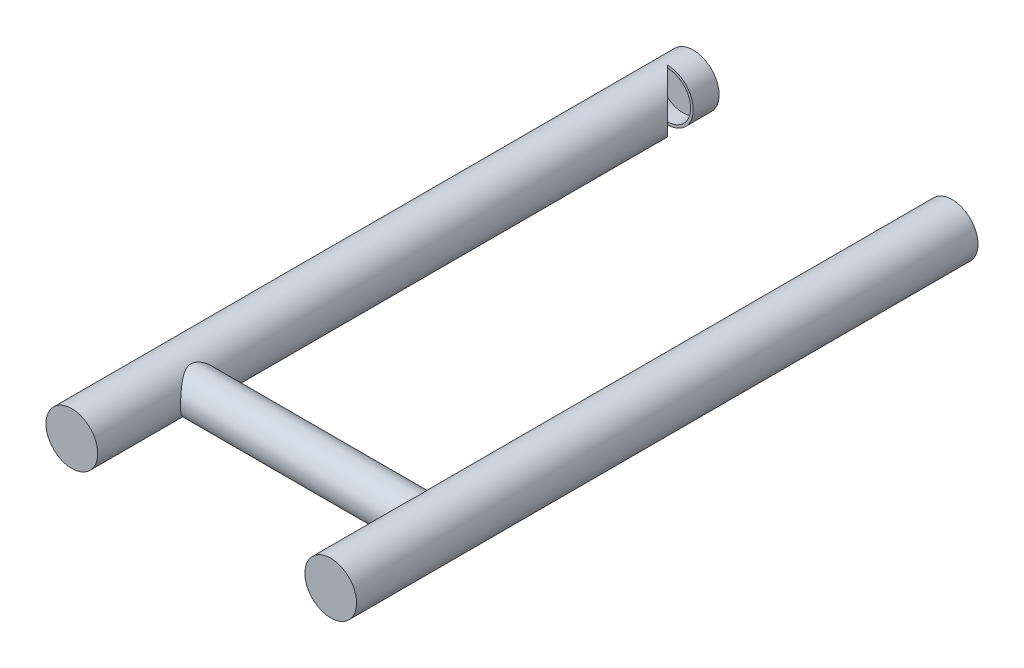
from build123d import *

# Parameters (mm, degrees)
SKETCH1_R                            = 12.7
BOSS_EXTRUDE2_DEPTH                  = 304.8
BOSS_EXTRUDE2_2_DEPTH                = 304.8
SKETCH10_R                           = 11.43
CUT_EXTRUDE1_DEPTH                   = 304.8
SKETCH11_R                           = 11.43
BOSS_EXTRUDE3_DEPTH                  = 5.08
SKETCH12_R                           = 11.43
BOSS_EXTRUDE4_DEPTH                  = 5.08
CUT_EXTRUDE2_DEPTH                   = 13.97
SKETCH14_R                           = 11.43
CUT_EXTRUDE3_DEPTH                   = 299.72
BOSS_EXTRUDE5_REACH                  = 316.437
BOSS_EXTRUDE5_END_RADIUS             = 12.7
SKETCH15_R                           = 10.16
BOSS_EXTRUDE5_DIRECTION_2_REACH      = 316.437
BOSS_EXTRUDE5_DIRECTION_2_END_RADIUS = 12.7
CUT_EXTRUDE4_REACH                   = 337.53
CUT_EXTRUDE4_END_RADIUS              = 11.43
SKETCH17_R                           = 8.89


with BuildPart() as part:
    # Sketch1 → Boss-Extrude2 (new body)
    with BuildSketch(Plane.XY):
        with Locations(Location((0, 0, 0), (0, 0, 180))):
            Circle(SKETCH1_R)
    extrude(amount=BOSS_EXTRUDE2_DEPTH)

    # Sketch10 → Cut-Extrude1 (cut)
    with BuildSketch(Plane(origin=(0, 0, 0), x_dir=(-1, 0, 0), z_dir=(0, 0, -1))):
        Circle(SKETCH10_R)
    extrude(amount=-CUT_EXTRUDE1_DEPTH, mode=Mode.SUBTRACT)

    # Sketch11 → Boss-Extrude3 (add)
    with BuildSketch(Plane(origin=(0, 0, 0), x_dir=(-1, 0, 0), z_dir=(0, 0, -1))):
        Circle(SKETCH11_R)
    extrude(amount=-BOSS_EXTRUDE3_DEPTH)

    # Sketch12 → Boss-Extrude4 (add)
    with BuildSketch(Plane.XY.offset(304.8)):
        with Locations(Location((0, 0, 0), (0, 0, 180))):
            Circle(SKETCH12_R)
    extrude(amount=-BOSS_EXTRUDE4_DEPTH)

    # Sketch3 → Cut-Extrude2 (cut, symmetric)
    with BuildSketch(Plane(origin=(0, 0, 0), x_dir=(1, 0, 0), z_dir=(0, 1, 0))):
        Polygon((12.7, -12.7), (0, -12.7), (12.7, -25.4), align=None)
    extrude(amount=CUT_EXTRUDE2_DEPTH, both=True, mode=Mode.SUBTRACT)



with BuildPart() as body_2:
    # Sketch1 → Boss-Extrude2 2 (new body)
    with BuildSketch(Plane.XY):
        with Locations(Location((127, 0, 0), (0, 0, 180))):
            Circle(SKETCH1_R)
    extrude(amount=BOSS_EXTRUDE2_2_DEPTH)

    # Sketch14 → Cut-Extrude3 (cut)
    with BuildSketch(Plane(origin=(0, 0, 0), x_dir=(-1, 0, 0), z_dir=(0, 0, -1))):
        with Locations((-127, 0)):
            Circle(SKETCH14_R)
    extrude(amount=-CUT_EXTRUDE3_DEPTH, mode=Mode.SUBTRACT)


with BuildPart() as part_1:
    add(part.part)

    add(body_2.part)  # Boss-Extrude5 merges body 2
    # Boss-Extrude5: up to this cylinder (the profile starts outside it)
    boss_extrude5_end = Plane(origin=(127, 0, 254), z_dir=(0, 0, -1)) * Cylinder(BOSS_EXTRUDE5_END_RADIUS, 659.274, mode=Mode.PRIVATE)
    # Sketch15 → Boss-Extrude5 (add, up to the surface)
    with BuildSketch(Plane(origin=(63.5, 0, 0), x_dir=(0, 0, -1), z_dir=(1, 0, 0)), mode=Mode.PRIVATE) as boss_extrude5_sk1:
        with Locations(Location((-254, 0, 0), (0, 0, 180))):
            Circle(SKETCH15_R)
    boss_extrude5_tool1 = extrude(boss_extrude5_sk1.sketch, amount=BOSS_EXTRUDE5_REACH, mode=Mode.PRIVATE) - boss_extrude5_end
    add(boss_extrude5_tool1.solids().sort_by_distance((63.5, 0, 254))[0])

    # Boss-Extrude5 direction 2: up to this cylinder (the profile starts outside it)
    boss_extrude5_direction_2_end = Plane(origin=(0, 0, 254), z_dir=(0, 0, -1)) * Cylinder(BOSS_EXTRUDE5_DIRECTION_2_END_RADIUS, 659.274, mode=Mode.PRIVATE)
    # Sketch15 → Boss-Extrude5 direction 2 (add, up to the surface)
    with BuildSketch(Plane(origin=(63.5, 0, 0), x_dir=(0, 0, -1), z_dir=(1, 0, 0)), mode=Mode.PRIVATE) as boss_extrude5_direction_2_sk1:
        with Locations(Location((-254, 0, 0), (0, 0, 180))):
            Circle(SKETCH15_R)
    boss_extrude5_direction_2_tool1 = extrude(boss_extrude5_direction_2_sk1.sketch, amount=-BOSS_EXTRUDE5_DIRECTION_2_REACH, mode=Mode.PRIVATE) - boss_extrude5_direction_2_end
    add(boss_extrude5_direction_2_tool1.solids().sort_by_distance((63.5, 0, 254))[0])

    # Cut-Extrude4: up to this cylinder (the profile starts outside it)
    cut_extrude4_end = Plane(origin=(127, 0, 254), z_dir=(0, 0, -1)) * Cylinder(CUT_EXTRUDE4_END_RADIUS, 698.92, mode=Mode.PRIVATE)
    # Sketch17 → Cut-Extrude4 (cut, up to the surface)
    with BuildSketch(Plane(origin=(0, 0, 0), x_dir=(0, 0, -1), z_dir=(1, 0, 0)), mode=Mode.PRIVATE) as cut_extrude4_sk1:
        with Locations(Location((-254, 0, 0), (0, 0, 180))):
            Circle(SKETCH17_R)
    cut_extrude4_tool1 = extrude(cut_extrude4_sk1.sketch, amount=CUT_EXTRUDE4_REACH, mode=Mode.PRIVATE) - cut_extrude4_end
    add(cut_extrude4_tool1.solids().sort_by_distance((0, 0, 254))[0], mode=Mode.SUBTRACT)


solid = part_1.part
